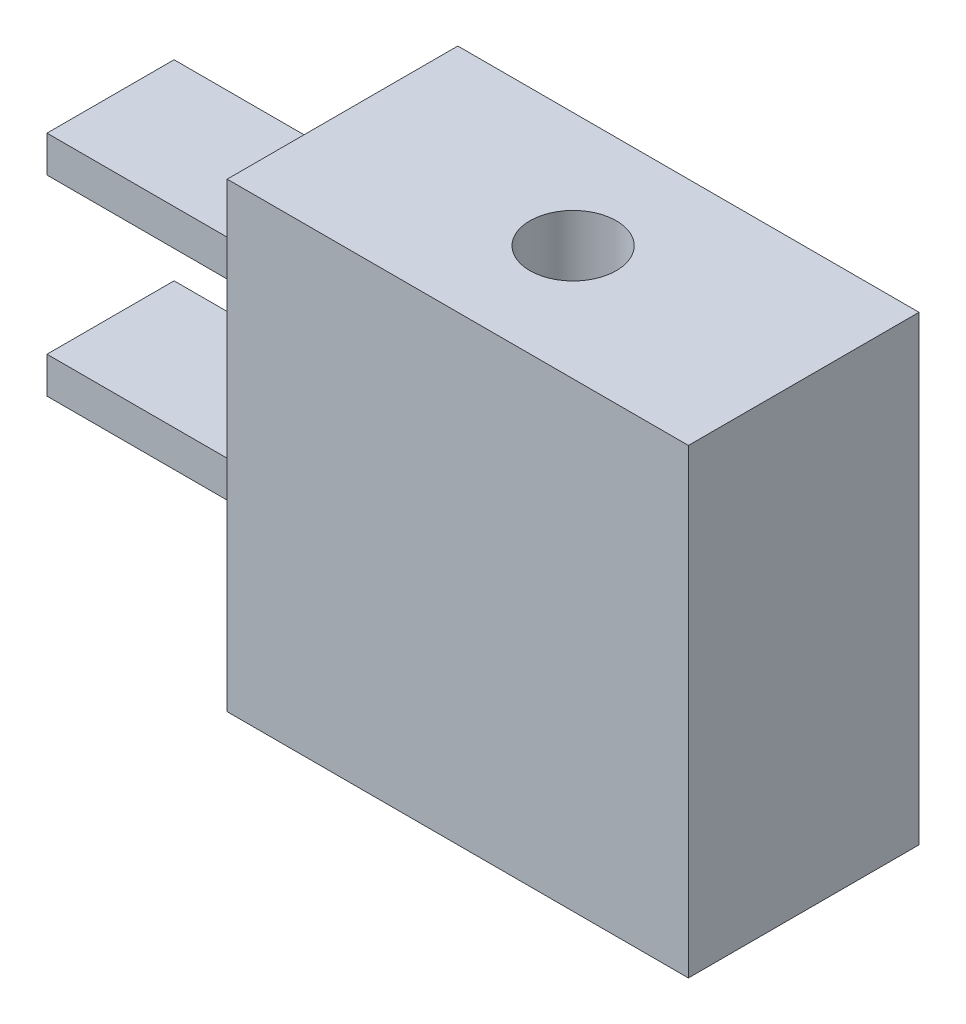
from build123d import *

# Parameters (mm, degrees)
SKETCH1_W           = 12.7
SKETCH1_H           = 6.35
BOSS_EXTRUDE1_DEPTH = 12.7
SKETCH2_R           = 1.190625
CUT_EXTRUDE1_DEPTH  = 3
SKETCH3_W           = 3.5
SKETCH3_H           = 1
BOSS_EXTRUDE2_DEPTH = 6.35


with BuildPart() as part:
    # Sketch1 → Boss-Extrude1 (new body)
    with BuildSketch(Plane(origin=(0, 0, 0), x_dir=(1, 0, 0), z_dir=(0, 1, 0))):
        Rectangle(SKETCH1_W, SKETCH1_H)
    extrude(amount=BOSS_EXTRUDE1_DEPTH)

    # Sketch2 → Cut-Extrude1 (cut)
    with BuildSketch(Plane(origin=(0, 12.7, 0), x_dir=(1, 0, 0), z_dir=(0, 1, 0))):
        Circle(SKETCH2_R)
    extrude(amount=-CUT_EXTRUDE1_DEPTH, mode=Mode.SUBTRACT)

    # Sketch3 → Boss-Extrude2 (add)
    with BuildSketch(Plane.ZY.offset(6.35)):
        with Locations((0.037458048, 4.156500498)):
            Rectangle(SKETCH3_W, SKETCH3_H)
        with Locations((0.037458048, 9.428549286)):
            Rectangle(SKETCH3_W, SKETCH3_H)
    extrude(amount=BOSS_EXTRUDE2_DEPTH)


solid = part.part
